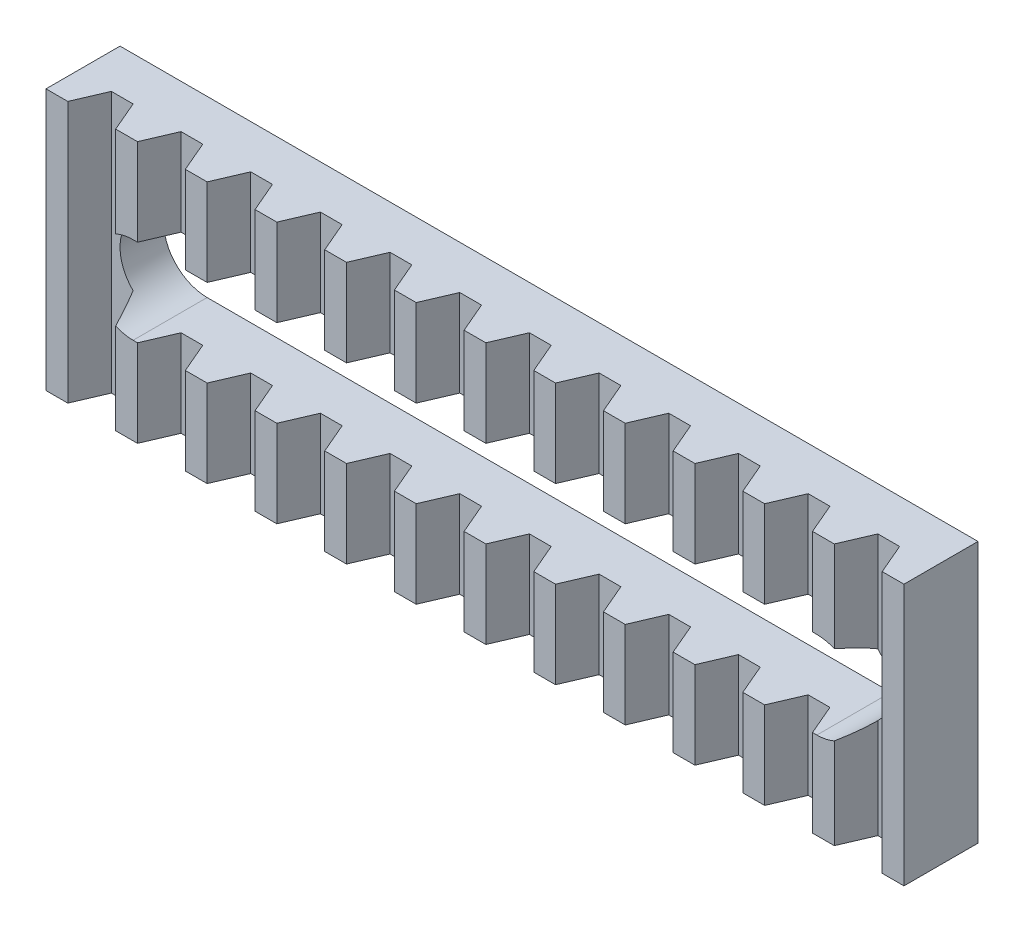
from build123d import *

# Parameters (mm, degrees)
BOSS_EXTRUDE1_DEPTH = 60
CUT_EXTRUDE1_DEPTH  = 30


with BuildPart() as part:
    # Sketch1 → Boss-Extrude1 (new body)
    with BuildSketch(Plane(origin=(0, 0, 0), x_dir=(1, 0, 0), z_dir=(0, 1, 0))):
        Polygon((-98.5, 0), (98.5, 0), (98.5, -17), (93.5, -17), (90.5, -10), (85.5, -10), (82.5, -17), (77.5, -17), (74.5, -10), (69.5, -10), (66.5, -17), (61.5, -17), (58.5, -10), (53.5, -10), (50.5, -17), (45.5, -17), (42.5, -10), (37.5, -10), (34.5, -17), (29.5, -17), (26.5, -10), (21.5, -10), (18.5, -17), (13.5, -17), (10.5, -10), (5.5, -10), (2.5, -17), (-2.5, -17), (-5.5, -10), (-10.5, -10), (-13.5, -17), (-18.5, -17), (-21.5, -10), (-26.5, -10), (-29.5, -17), (-34.5, -17), (-37.5, -10), (-42.5, -10), (-45.5, -17), (-50.5, -17), (-53.5, -10), (-58.5, -10), (-61.5, -17), (-66.5, -17), (-69.5, -10), (-74.5, -10), (-77.5, -17), (-82.5, -17), (-85.5, -10), (-90.5, -10), (-93.5, -17), (-98.5, -17), align=None)
    extrude(amount=BOSS_EXTRUDE1_DEPTH)

    # Sketch2 → Cut-Extrude1 (cut, symmetric)
    with BuildSketch(Plane.XY):
        with BuildLine():
            Line((-78.5, 40), (78.5, 40))
            ThreePointArc((78.5, 40), (88.5, 30), (78.5, 20))
            Line((78.5, 20), (-78.5, 20))
            ThreePointArc((-78.5, 20), (-88.5, 30), (-78.5, 40))
        make_face()
    extrude(amount=CUT_EXTRUDE1_DEPTH, both=True, mode=Mode.SUBTRACT)


solid = part.part
